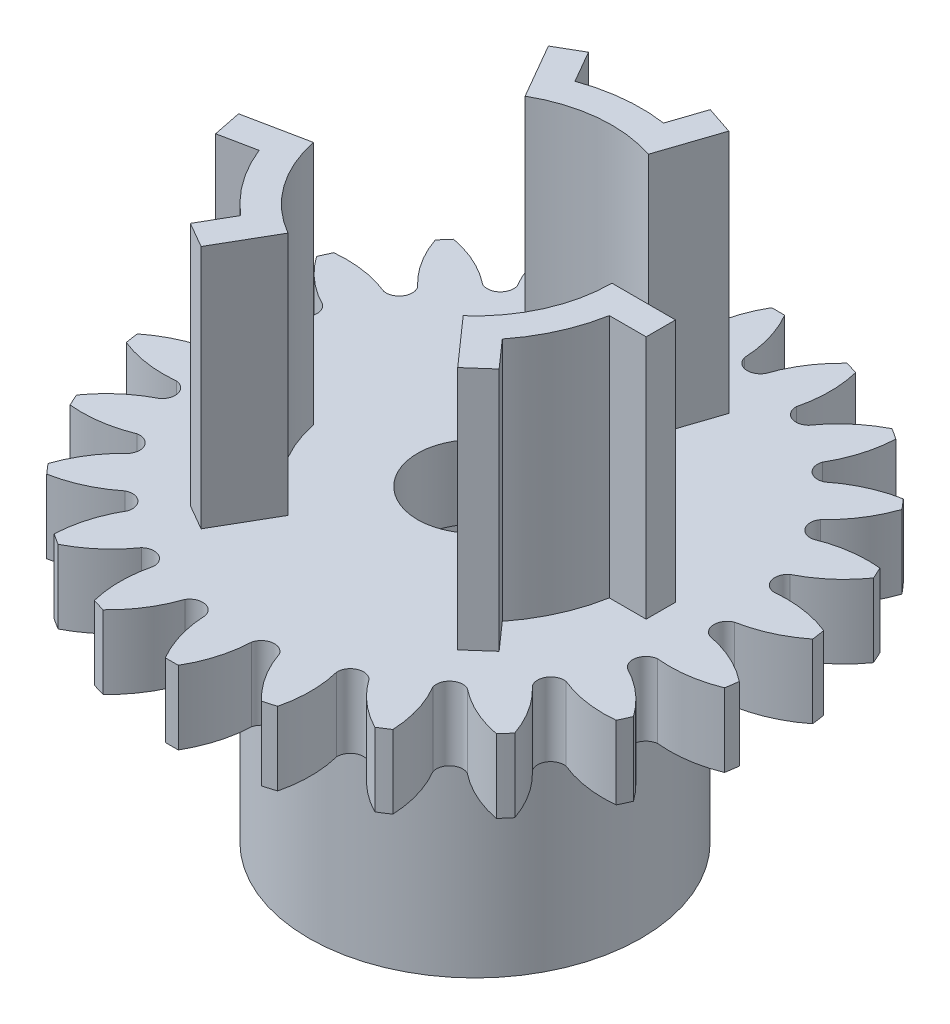
from build123d import *

# Parameters (mm, degrees)
SKETCH1_R           = 6.8
BOSS_EXTRUDE1_DEPTH = 12.6
SKETCH2_R           = 5.8
CUT_EXTRUDE1_DEPTH  = 13.6
SKETCH3_R           = 12.4
BOSS_EXTRUDE3_DEPTH = 3
SKETCH4_R           = 2.35
CUT_EXTRUDE2_DEPTH  = 3
CUT_EXTRUDE3_DEPTH  = 3
CIRPATTERN1_COUNT   = 22
BOSS_EXTRUDE4_DEPTH = 10


with BuildPart() as part:
    # Sketch1 → Boss-Extrude1 (new body)
    with BuildSketch(Plane(origin=(0, 0, 0), x_dir=(1, 0, 0), z_dir=(0, 1, 0))):
        Circle(SKETCH1_R)
    extrude(amount=BOSS_EXTRUDE1_DEPTH)

    # Sketch2 → Cut-Extrude1 (cut, through all)
    with BuildSketch(Plane.XZ):
        Circle(SKETCH2_R)
    extrude(amount=-CUT_EXTRUDE1_DEPTH, mode=Mode.SUBTRACT)

    # Sketch3 → Boss-Extrude3 (add)
    with BuildSketch(Plane(origin=(0, 12.6, 0), x_dir=(1, 0, 0), z_dir=(0, 1, 0))):
        Circle(SKETCH3_R)
    extrude(amount=-BOSS_EXTRUDE3_DEPTH)

    # Sketch4 → Cut-Extrude2 (cut)
    with BuildSketch(Plane(origin=(0, 12.6, 0), x_dir=(1, 0, 0), z_dir=(0, 1, 0))):
        Circle(SKETCH4_R)
    extrude(amount=-CUT_EXTRUDE2_DEPTH, mode=Mode.SUBTRACT)

    # Sketch5 → Cut-Extrude3 (cut)
    with BuildSketch(Plane(origin=(0, 12.6, 0), x_dir=(1, 0, 0), z_dir=(0, 1, 0))):
        with BuildLine():
            ThreePointArc((12.308939841, -1.5), (12.4, 0), (12.308939841, 1.5))
            ThreePointArc((12.308939841, 1.5), (11.269957917, 0.865760233), (10.108939841, 0.5))
            ThreePointArc((10.108939841, 0.5), (9.773209975, 0), (10.108939841, -0.5))
            ThreePointArc((10.108939841, -0.5), (11.269957917, -0.865760233), (12.308939841, -1.5))
        make_face()
    cut_extrude3 = extrude(amount=-CUT_EXTRUDE3_DEPTH, mode=Mode.SUBTRACT)

    # CirPattern1: Cut-Extrude3 ×22 about axis
    cirpattern1_axis = Axis((0, 0, 0), (0, 1, 0))
    for i in range(1, CIRPATTERN1_COUNT):
        add(cut_extrude3.rotate(cirpattern1_axis, i * 360 / CIRPATTERN1_COUNT), mode=Mode.SUBTRACT)

    # Sketch6 → Boss-Extrude4 (add)
    with BuildSketch(Plane(origin=(0, 12.6, 0), x_dir=(1, 0, 0), z_dir=(0, 1, 0))):
        with BuildLine():
            Line((8.2, 0), (5.6, 0))
            ThreePointArc((5.6, 0), (5.105878964, -2.3), (3.710714286, -4.194114864))
            Line((3.710714286, -4.194114864), (5.433545918, -6.141382479))
            Line((5.433545918, -6.141382479), (6.332284818, -5.346229418))
            Line((6.332284818, -5.346229418), (5.333890775, -4.217773015))
            ThreePointArc((5.333890775, -4.217773015), (6.199995885, -2.792857143), (6.693280212, -1.2))
            Line((6.693280212, -1.2), (8.2, -1.2))
            Line((8.2, -1.2), (8.2, 0))
        make_face()
        with BuildLine():
            Line((-8.0353662, -1.634897558), (-7.796112899, -2.810804807))
            Line((-7.796112899, -2.810804807), (-6.319643965, -2.510398405))
            ThreePointArc((-6.319643965, -2.510398405), (-5.518683178, -3.972925369), (-4.385870591, -5.196550698))
            Line((-4.385870591, -5.196550698), (-5.139230485, -6.501408311))
            Line((-5.139230485, -6.501408311), (-4.1, -7.101408311))
            Line((-4.1, -7.101408311), (-2.8, -4.849742261))
            ThreePointArc((-2.8, -4.849742261), (-4.544797911, -3.271820892), (-5.487567161, -1.116515406))
            Line((-5.487567161, -1.116515406), (-8.0353662, -1.634897558))
        make_face()
        with BuildLine():
            Line((2.601820282, 7.776280037), (1.463828081, 8.157034225))
            Line((1.463828081, 8.157034225), (0.985753191, 6.728171419))
            ThreePointArc((0.985753191, 6.728171419), (-0.681312708, 6.765782512), (-2.307409622, 6.396550698))
            Line((-2.307409622, 6.396550698), (-3.060769515, 7.701408311))
            Line((-3.060769515, 7.701408311), (-4.1, 7.101408311))
            Line((-4.1, 7.101408311), (-2.8, 4.849742261))
            ThreePointArc((-2.8, 4.849742261), (-0.561081054, 5.571820892), (1.776852875, 5.310630269))
            Line((1.776852875, 5.310630269), (2.601820282, 7.776280037))
        make_face()
    extrude(amount=BOSS_EXTRUDE4_DEPTH)


solid = part.part
